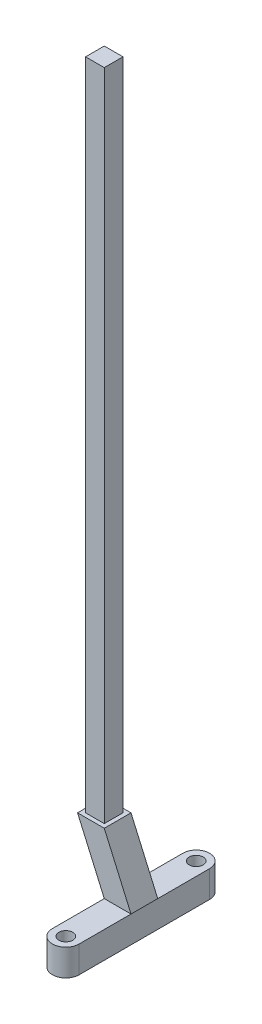
from build123d import *

# Parameters (mm, degrees)
BOSS_EXTRUDE1_DEPTH = 6.35
SKETCH2_R           = 1.651
BOSS_EXTRUDE2_DEPTH = 6.35
SKETCH4_W           = 4.445
SKETCH4_H           = 4.445
BOSS_EXTRUDE3_DEPTH = 155.575


with BuildPart() as part:
    # Sketch1 → Boss-Extrude1 (new body)
    with BuildSketch(Plane.XY):
        Polygon((0, 0), (6.35, 0), (0, 14.478), (-6.35, 14.478), align=None)
    extrude(amount=BOSS_EXTRUDE1_DEPTH)

    # Sketch2 → Boss-Extrude2 (add)
    with BuildSketch(Plane.XZ):
        with BuildLine():
            Line((6.35, 18.669), (6.35, -12.319))
            ThreePointArc((6.35, -12.319), (3.175, -15.494), (0, -12.319))
            Line((0, -12.319), (0, 18.669))
            ThreePointArc((0, 18.669), (3.175, 21.844), (6.35, 18.669))
        make_face()
        with Locations((3.175, 18.669)):
            Circle(SKETCH2_R, mode=Mode.SUBTRACT)
        with Locations((3.175, -12.319)):
            Circle(SKETCH2_R, mode=Mode.SUBTRACT)
    extrude(amount=BOSS_EXTRUDE2_DEPTH)

    # Sketch4 → Boss-Extrude3 (add)
    with BuildSketch(Plane(origin=(0, 14.478, 0), x_dir=(1, 0, 0), z_dir=(0, 1, 0))):
        with Locations((-3.175, -3.175)):
            Rectangle(SKETCH4_W, SKETCH4_H)
    extrude(amount=BOSS_EXTRUDE3_DEPTH)


solid = part.part
